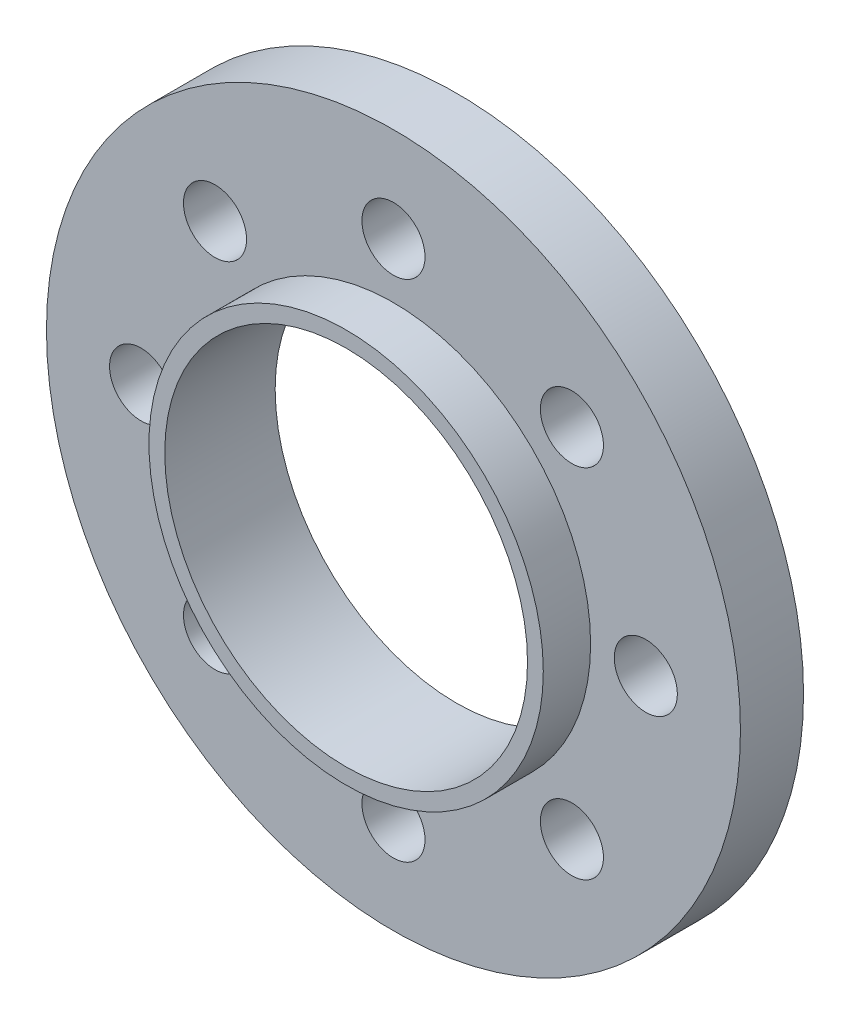
from build123d import *

# Parameters (mm, degrees)
SKETCH1_R           = 11
SKETCH1_R_2         = 1
BOSS_EXTRUDE1_DEPTH = 2
SKETCH2_R           = 6.25
BOSS_EXTRUDE2_DEPTH = 1.5
SKETCH3_R           = 5.75
CUT_EXTRUDE1_DEPTH  = 11


with BuildPart() as part:
    # Sketch1 → Boss-Extrude1 (new body)
    with BuildSketch(Plane.XY):
        Circle(SKETCH1_R)
        with Locations((0, 8)):
            Circle(SKETCH1_R_2, mode=Mode.SUBTRACT)
        with Locations((5.656854249, 5.656854249)):
            Circle(SKETCH1_R_2, mode=Mode.SUBTRACT)
        with Locations((8, 0)):
            Circle(SKETCH1_R_2, mode=Mode.SUBTRACT)
        with Locations((5.656854249, -5.656854249)):
            Circle(SKETCH1_R_2, mode=Mode.SUBTRACT)
        with Locations((0, -8)):
            Circle(SKETCH1_R_2, mode=Mode.SUBTRACT)
        with Locations((-5.656854249, -5.656854249)):
            Circle(SKETCH1_R_2, mode=Mode.SUBTRACT)
        with Locations((-8, 0)):
            Circle(SKETCH1_R_2, mode=Mode.SUBTRACT)
        with Locations((-5.656854249, 5.656854249)):
            Circle(SKETCH1_R_2, mode=Mode.SUBTRACT)
    extrude(amount=BOSS_EXTRUDE1_DEPTH)

    # Sketch2 → Boss-Extrude2 (add)
    with BuildSketch(Plane.XY.offset(2)):
        Circle(SKETCH2_R)
    extrude(amount=BOSS_EXTRUDE2_DEPTH)

    # Sketch3 → Cut-Extrude1 (cut)
    with BuildSketch(Plane.XY.offset(3.5)):
        Circle(SKETCH3_R)
    extrude(amount=-CUT_EXTRUDE1_DEPTH, mode=Mode.SUBTRACT)


solid = part.part
